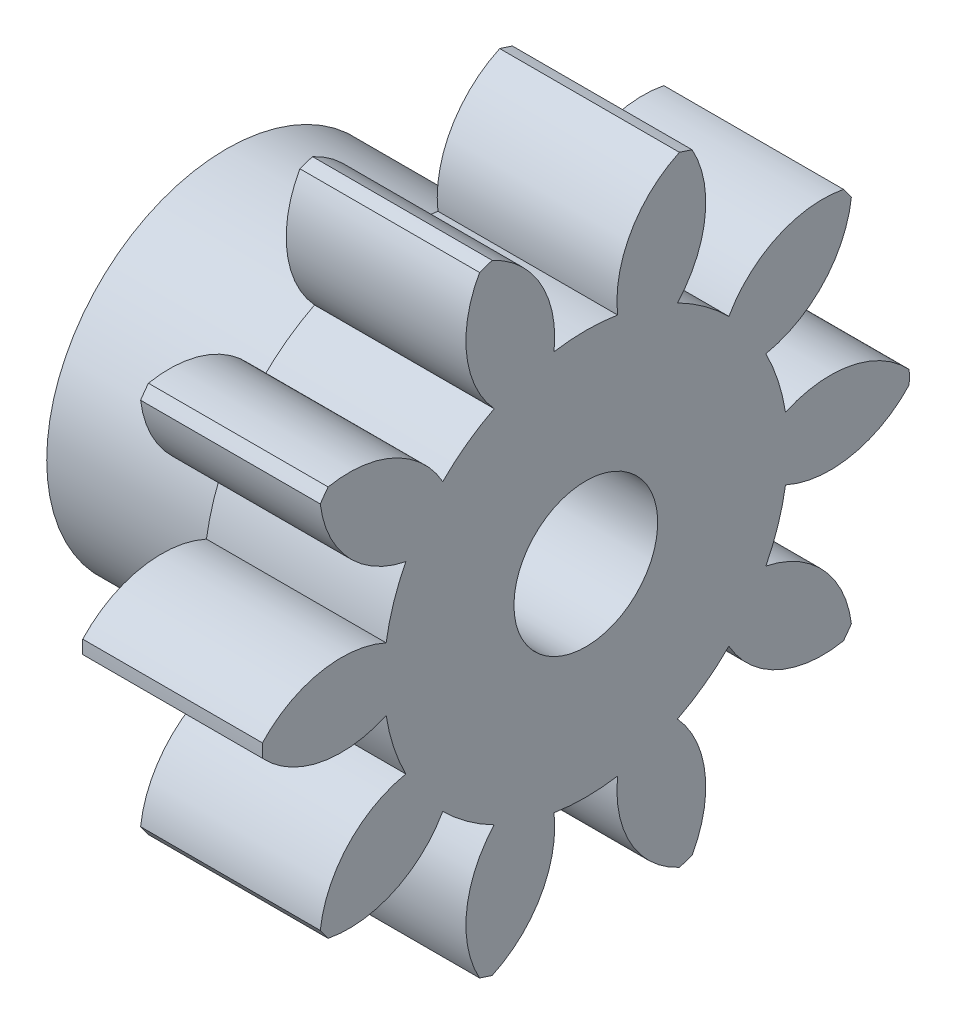
from build123d import *

# Parameters (mm, degrees)
BASPROSKE_W        = 10
BASPROSKE_H        = 18
TOOTHCUT_DEPTH     = 28.349588662
TEETHCUTS_COUNT    = 10
TEETHCUTS_ANGLE    = 324
HUBNEAONESKE_R     = 10
HUBNEARONE_DEPTH   = 10.0000508
BORSKE_R           = 3.5
BORE_DEPTH         = 20.0000508
CUT_EXTRUDE1_DEPTH = 6
SKETCH2_R          = 4
CUT_EXTRUDE2_DEPTH = 29.581121206
SKETCH3_R          = 2.25
CUT_EXTRUDE3_DEPTH = 27.8492101


with BuildPart() as part:
    # BasProSke → Base-Revolve (revolve)
    with BuildSketch(Plane(origin=(0, 0, 0), x_dir=(1, 0, 0), z_dir=(0, 1, 0)), mode=Mode.PRIVATE) as base_revolve_sk:
        with Locations((5, 9)):
            Rectangle(BASPROSKE_W, BASPROSKE_H)
    revolve(base_revolve_sk.sketch.rotate(Axis((-10, 0, 0), (1, 0, 0)), 180), axis=Axis((-10, 0, 0), (1, 0, 0)))

    # TooCutSke → ToothCut (cut, through all)
    with BuildSketch(Plane(origin=(0, 0, 0), x_dir=(0, 0, -1), z_dir=(1, 0, 0))):
        with BuildLine():
            ThreePointArc((1.768949054, 11.109042274), (0, 11.249), (-1.768949054, 11.109042274))
            ThreePointArc((-1.768949054, 11.109042274), (-2.508977513, 14.741789417), (-5.242576524, 17.246171649))
            ThreePointArc((-5.242576524, 17.246171649), (0, 18.0254), (5.242576524, 17.246171649))
            ThreePointArc((5.242576524, 17.246171649), (2.508977513, 14.741789417), (1.768949054, 11.109042274))
        make_face()
    toothcut = extrude(amount=TOOTHCUT_DEPTH, mode=Mode.SUBTRACT)

    # TeethCuts: ToothCut ×10 about axis
    teethcuts_axis = Axis((-10, 0, 0), (1, 0, 0))
    for i in range(1, TEETHCUTS_COUNT):
        add(toothcut.rotate(teethcuts_axis, i * TEETHCUTS_ANGLE / (TEETHCUTS_COUNT - 1)), mode=Mode.SUBTRACT)

    # HubNeaOneSke → HubNearOne (add)
    with BuildSketch(Plane.ZY):
        with Locations(Location((0, 0, 0), (0, 0, 180))):
            Circle(HUBNEAONESKE_R)
    extrude(amount=HUBNEARONE_DEPTH)

    # BorSke → Bore (cut, symmetric)
    with BuildSketch(Plane(origin=(0, 0, 0), x_dir=(0, 0, -1), z_dir=(1, 0, 0))):
        with Locations(Location((0, 0, 0), (0, 0, 180))):
            Circle(BORSKE_R)
    extrude(amount=BORE_DEPTH, both=True, mode=Mode.SUBTRACT)

    # Sketch1 → Cut-Extrude1 (cut)
    with BuildSketch(Plane.ZY.offset(10.0000508)):
        Polygon((7.794228634, 0), (3.897114317, 6.75), (-3.897114317, 6.75), (-7.794228634, 0), (-3.897114317, -6.75), (3.897114317, -6.75), align=None)
    extrude(amount=-CUT_EXTRUDE1_DEPTH, mode=Mode.SUBTRACT)

    # Sketch2 → Cut-Extrude2 (cut, through all)
    with BuildSketch(Plane.ZY.offset(4.0000508)):
        Circle(SKETCH2_R)
    extrude(amount=-CUT_EXTRUDE2_DEPTH, mode=Mode.SUBTRACT)

    # Sketch3 → Cut-Extrude3 (cut, through all)
    with BuildSketch(Plane(origin=(0, 0, 0), x_dir=(1, 0, 0), z_dir=(0, 1, 0))):
        with Locations(Location((-7.0000508, 0, 0), (0, 0, 270))):
            Circle(SKETCH3_R)
    extrude(amount=-CUT_EXTRUDE3_DEPTH, mode=Mode.SUBTRACT)


solid = part.part
